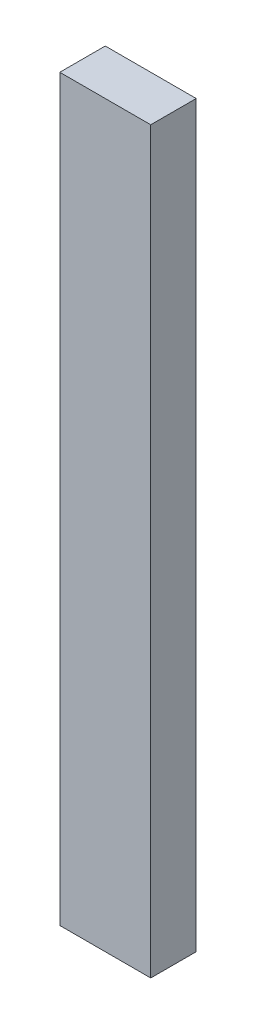
from build123d import *

# Parameters (mm, degrees)
SKETCH1_W           = 2.032
SKETCH1_H           = 16.51
BOSS_EXTRUDE1_DEPTH = 1.016


with BuildPart() as part:
    # Sketch1 → Boss-Extrude1 (new body)
    with BuildSketch(Plane.XY):
        with Locations((1.016, -8.255)):
            Rectangle(SKETCH1_W, SKETCH1_H)
    extrude(amount=BOSS_EXTRUDE1_DEPTH)


solid = part.part
